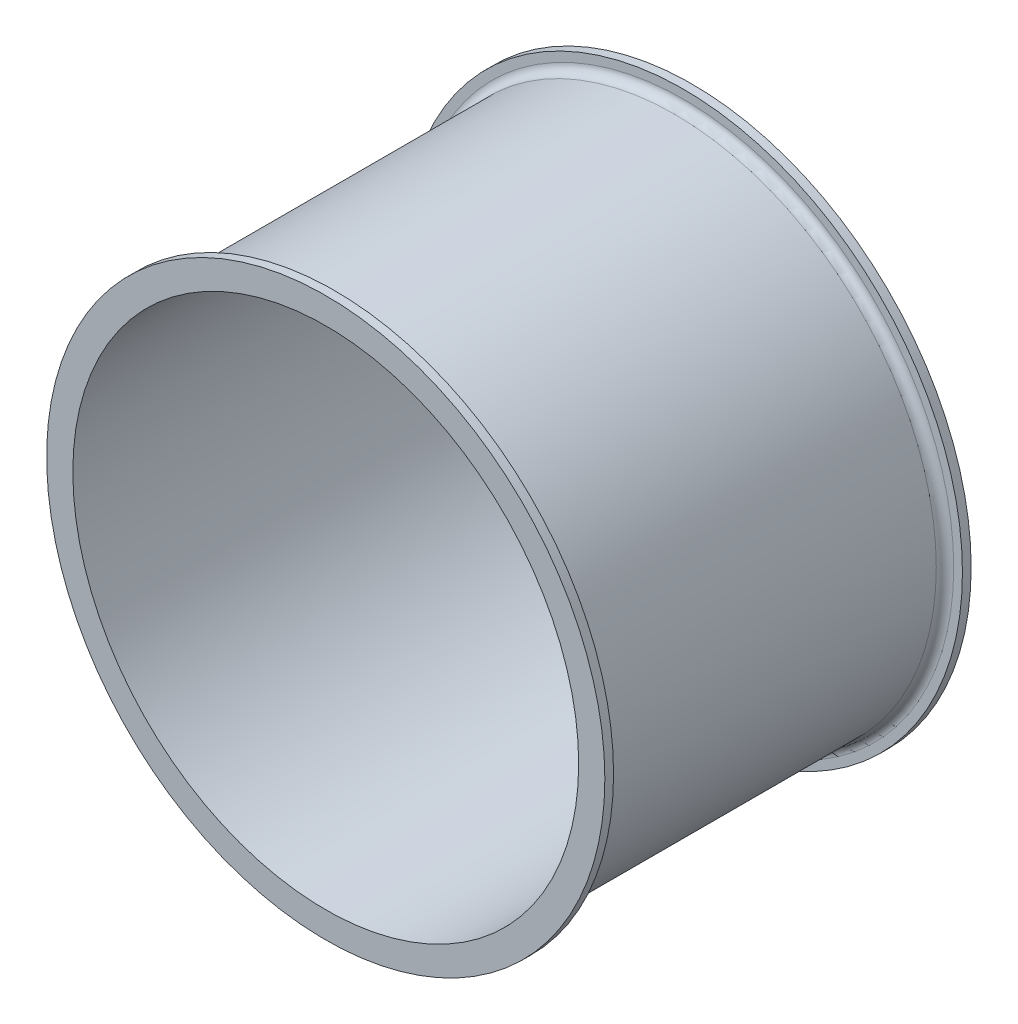
from build123d import *

# Parameters (mm, degrees)
IZIM1_R                     = 160
Y_KSEKLIK_EKSTR_ZYON1_DEPTH = 5
IZIM2_R                     = 150
Y_KSEKLIK_EKSTR_ZYON2_DEPTH = 200
IZIM3_R                     = 160
Y_KSEKLIK_EKSTR_ZYON3_DEPTH = 5
IZIM4_R                     = 145
KES_EKSTR_ZYON1_DEPTH       = 210
RADYUS1_R                   = 5


with BuildPart() as part:
    # Çizim1 → Yükseklik-Ekstrüzyon1 (new body)
    with BuildSketch(Plane.XY):
        Circle(IZIM1_R)
    extrude(amount=Y_KSEKLIK_EKSTR_ZYON1_DEPTH)

    # Çizim2 → Yükseklik-Ekstrüzyon2 (add)
    with BuildSketch(Plane.XY.offset(5)):
        Circle(IZIM2_R)
    extrude(amount=Y_KSEKLIK_EKSTR_ZYON2_DEPTH)

    # Çizim3 → Yükseklik-Ekstrüzyon3 (add)
    with BuildSketch(Plane.XY.offset(205)):
        Circle(IZIM3_R)
    extrude(amount=Y_KSEKLIK_EKSTR_ZYON3_DEPTH)

    # Çizim4 → Kes-Ekstrüzyon1 (cut)
    with BuildSketch(Plane(origin=(0, 0, 0), x_dir=(-1, 0, 0), z_dir=(0, 0, -1))):
        Circle(IZIM4_R)
    extrude(amount=-KES_EKSTR_ZYON1_DEPTH, mode=Mode.SUBTRACT)

    # Radyus1
    radyus1_edges = [part.edges().sort_by_distance(p)[0] for p in [
        (-150, 0, 5),
        (-150, 0, 205),
    ]]
    fillet(radyus1_edges, radius=RADYUS1_R)


solid = part.part
